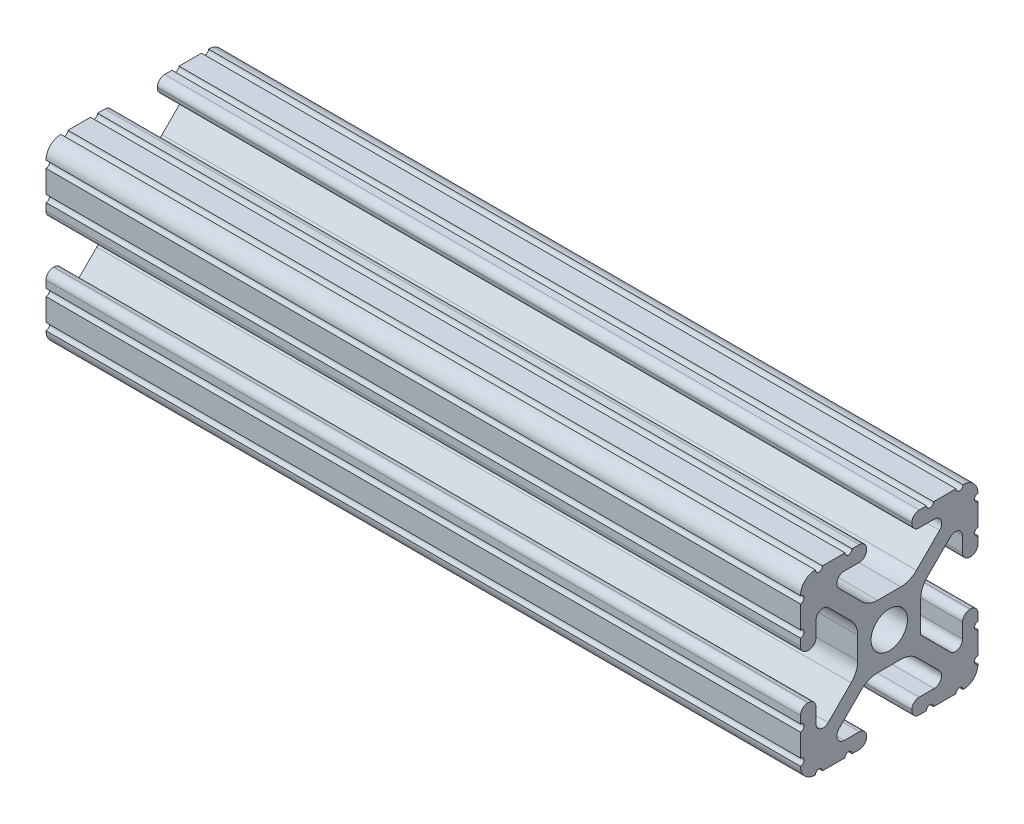
from build123d import *

# Parameters (mm, degrees)
SKETCH1_R               = 2.6035
BOSS_EXTRUDE1_DEPTH     = 107.95
SKETCH2_R               = 3.175
CUT_EXTRUDE1_DEPTH      = 13.7
CUT_EXTRUDE1_DEPTH_BACK = 13.7


with BuildPart() as part:
    # Sketch1 → Boss-Extrude1 (new body)
    with BuildSketch(Plane(origin=(0, 0, 0), x_dir=(0, 0, -1), z_dir=(1, 0, 0))):
        with BuildLine():
            Line((6.333126718, -12.7), (9.550443118, -12.7))
            ThreePointArc((9.550443118, -12.7), (10.058366869, -12.192000006), (10.566443095, -12.699847501))
            ThreePointArc((10.566443095, -12.699847501), (12.082537762, -12.08250727), (12.699846982, -10.566399977))
            ThreePointArc((12.699846982, -10.566399977), (12.192000006, -10.058323491), (12.7, -9.5504))
            Line((12.7, -9.5504), (12.7, -6.3330836))
            ThreePointArc((12.7, -6.3330836), (12.192, -5.8250836), (12.7, -5.3170836))
            Line((12.7, -5.3170836), (12.7, -4.287469289))
            ThreePointArc((12.7, -4.287469289), (12.39275138, -3.545705502), (11.650987593, -3.238456882))
            Line((11.650987593, -3.238456882), (11.539212407, -3.238456882))
            ThreePointArc((11.539212407, -3.238456882), (10.79744862, -3.545705502), (10.4902, -4.287469289))
            Line((10.4902, -4.287469289), (10.4902, -6.402089023))
            ThreePointArc((10.4902, -6.402089023), (9.856505071, -7.351067942), (8.737131347, -7.129408934))
            Line((8.737131347, -7.129408934), (4.5085, -2.9104418))
            Line((4.5085, -2.9104418), (4.5085, 1.593185507))
            ThreePointArc((4.5085, 1.593185507), (4.750877967, 2.809883091), (5.441005833, 3.840816462))
            Line((5.441005833, 3.840816462), (8.737131347, 7.129408934))
            ThreePointArc((8.737131347, 7.129408934), (9.856505071, 7.351067942), (10.4902, 6.402089023))
            Line((10.4902, 6.402089023), (10.4902, 4.287469289))
            ThreePointArc((10.4902, 4.287469289), (10.79744862, 3.545705502), (11.539212407, 3.238456882))
            Line((11.539212407, 3.238456882), (11.650987593, 3.238456882))
            ThreePointArc((11.650987593, 3.238456882), (12.39275138, 3.545705502), (12.7, 4.287469289))
            Line((12.7, 4.287469289), (12.7, 5.3170836))
            ThreePointArc((12.7, 5.3170836), (12.192, 5.8250836), (12.7, 6.3330836))
            Line((12.7, 6.3330836), (12.7, 9.5504))
            ThreePointArc((12.7, 9.5504), (12.192000006, 10.058323491), (12.699846982, 10.566399977))
            ThreePointArc((12.699846982, 10.566399977), (12.082537762, 12.08250727), (10.566443095, 12.699847501))
            ThreePointArc((10.566443095, 12.699847501), (10.058366869, 12.192000006), (9.550443118, 12.7))
            Line((9.550443118, 12.7), (6.333126718, 12.7))
            ThreePointArc((6.333126718, 12.7), (5.825126718, 12.192), (5.317126718, 12.7))
            Line((5.317126718, 12.7), (4.287512407, 12.7))
            ThreePointArc((4.287512407, 12.7), (3.54574862, 12.39275138), (3.2385, 11.650987593))
            Line((3.2385, 11.650987593), (3.2385, 11.539212407))
            ThreePointArc((3.2385, 11.539212407), (3.54574862, 10.79744862), (4.287512407, 10.4902))
            Line((4.287512407, 10.4902), (6.476788598, 10.4902))
            ThreePointArc((6.476788598, 10.4902), (7.432222385, 9.85140422), (7.207036008, 8.724370562))
            Line((7.207036008, 8.724370562), (3.898272566, 5.423169045))
            ThreePointArc((3.898272566, 5.423169045), (2.869120213, 4.736787962), (1.655778399, 4.4958))
            Line((1.655778399, 4.4958), (-1.655778399, 4.4958))
            ThreePointArc((-1.655778399, 4.4958), (-2.869120213, 4.736787962), (-3.898272566, 5.423169045))
            Line((-3.898272566, 5.423169045), (-7.207036008, 8.724370562))
            ThreePointArc((-7.207036008, 8.724370562), (-7.432222385, 9.85140422), (-6.476788598, 10.4902))
            Line((-6.476788598, 10.4902), (-4.287512407, 10.4902))
            ThreePointArc((-4.287512407, 10.4902), (-3.54574862, 10.79744862), (-3.2385, 11.539212407))
            Line((-3.2385, 11.539212407), (-3.2385, 11.650987593))
            ThreePointArc((-3.2385, 11.650987593), (-3.54574862, 12.39275138), (-4.287512407, 12.7))
            Line((-4.287512407, 12.7), (-5.317126718, 12.7))
            ThreePointArc((-5.317126718, 12.7), (-5.825126718, 12.192), (-6.333126718, 12.7))
            Line((-6.333126718, 12.7), (-9.550443118, 12.7))
            ThreePointArc((-9.550443118, 12.7), (-10.058366869, 12.192000006), (-10.566443095, 12.699847501))
            ThreePointArc((-10.566443095, 12.699847501), (-12.082537762, 12.08250727), (-12.699846982, 10.566399977))
            ThreePointArc((-12.699846982, 10.566399977), (-12.192000006, 10.058323491), (-12.7, 9.5504))
            Line((-12.7, 9.5504), (-12.7, 6.3330836))
            ThreePointArc((-12.7, 6.3330836), (-12.192, 5.8250836), (-12.7, 5.3170836))
            Line((-12.7, 5.3170836), (-12.7, 4.287469289))
            ThreePointArc((-12.7, 4.287469289), (-12.39275138, 3.545705502), (-11.650987593, 3.238456882))
            Line((-11.650987593, 3.238456882), (-11.539212407, 3.238456882))
            ThreePointArc((-11.539212407, 3.238456882), (-10.79744862, 3.545705502), (-10.4902, 4.287469289))
            Line((-10.4902, 4.287469289), (-10.4902, 6.402089023))
            ThreePointArc((-10.4902, 6.402089023), (-9.856505071, 7.351067942), (-8.737131347, 7.129408934))
            Line((-8.737131347, 7.129408934), (-5.441005833, 3.840816462))
            ThreePointArc((-5.441005833, 3.840816462), (-4.750877967, 2.809883091), (-4.5085, 1.593185507))
            Line((-4.5085, 1.593185507), (-4.5085, -1.593185507))
            ThreePointArc((-4.5085, -1.593185507), (-4.750877967, -2.809883091), (-5.441005833, -3.840816462))
            Line((-5.441005833, -3.840816462), (-8.737131347, -7.129408934))
            ThreePointArc((-8.737131347, -7.129408934), (-9.856505071, -7.351067942), (-10.4902, -6.402089023))
            Line((-10.4902, -6.402089023), (-10.4902, -4.287469289))
            ThreePointArc((-10.4902, -4.287469289), (-10.79744862, -3.545705502), (-11.539212407, -3.238456882))
            Line((-11.539212407, -3.238456882), (-11.650987593, -3.238456882))
            ThreePointArc((-11.650987593, -3.238456882), (-12.39275138, -3.545705502), (-12.7, -4.287469289))
            Line((-12.7, -4.287469289), (-12.7, -5.3170836))
            ThreePointArc((-12.7, -5.3170836), (-12.192, -5.8250836), (-12.7, -6.3330836))
            Line((-12.7, -6.3330836), (-12.7, -9.5504))
            ThreePointArc((-12.7, -9.5504), (-12.192000006, -10.058323491), (-12.699846982, -10.566399977))
            ThreePointArc((-12.699846982, -10.566399977), (-12.082537762, -12.08250727), (-10.566443095, -12.699847501))
            ThreePointArc((-10.566443095, -12.699847501), (-10.058366869, -12.192000006), (-9.550443118, -12.7))
            Line((-9.550443118, -12.7), (-6.333126718, -12.7))
            ThreePointArc((-6.333126718, -12.7), (-5.825126718, -12.192), (-5.317126718, -12.7))
            Line((-5.317126718, -12.7), (-4.287512407, -12.7))
            ThreePointArc((-4.287512407, -12.7), (-3.54574862, -12.39275138), (-3.2385, -11.650987593))
            Line((-3.2385, -11.650987593), (-3.2385, -11.539212407))
            ThreePointArc((-3.2385, -11.539212407), (-3.54574862, -10.79744862), (-4.287512407, -10.4902))
            Line((-4.287512407, -10.4902), (-6.416408329, -10.4902))
            ThreePointArc((-6.416408329, -10.4902), (-7.41473083, -9.822813117), (-7.179650497, -8.645192506))
            Line((-7.179650497, -8.645192506), (-3.952270251, -5.423690499))
            ThreePointArc((-3.952270251, -5.423690499), (-2.922936451, -4.736929036), (-1.709253557, -4.4958))
            Line((-1.709253557, -4.4958), (1.709253557, -4.4958))
            ThreePointArc((1.709253557, -4.4958), (2.922936451, -4.736929036), (3.952270251, -5.423690499))
            Line((3.952270251, -5.423690499), (7.179650497, -8.645192506))
            ThreePointArc((7.179650497, -8.645192506), (7.41473083, -9.822813117), (6.416408329, -10.4902))
            Line((6.416408329, -10.4902), (4.287512407, -10.4902))
            ThreePointArc((4.287512407, -10.4902), (3.54574862, -10.79744862), (3.2385, -11.539212407))
            Line((3.2385, -11.539212407), (3.2385, -11.650987593))
            ThreePointArc((3.2385, -11.650987593), (3.54574862, -12.39275138), (4.287512407, -12.7))
            Line((4.287512407, -12.7), (5.317126718, -12.7))
            ThreePointArc((5.317126718, -12.7), (5.825126718, -12.192), (6.333126718, -12.7))
        make_face()
        Circle(SKETCH1_R, mode=Mode.SUBTRACT)
    extrude(amount=BOSS_EXTRUDE1_DEPTH)

    # Sketch2 → Cut-Extrude1 (cut, two sides)
    with BuildSketch(Plane.XY) as cut_extrude1_sk:
        with Locations((44.45, 0)):
            Circle(SKETCH2_R)
    extrude(amount=CUT_EXTRUDE1_DEPTH, mode=Mode.SUBTRACT)
    extrude(cut_extrude1_sk.sketch, amount=-CUT_EXTRUDE1_DEPTH_BACK, mode=Mode.SUBTRACT)


solid = part.part
